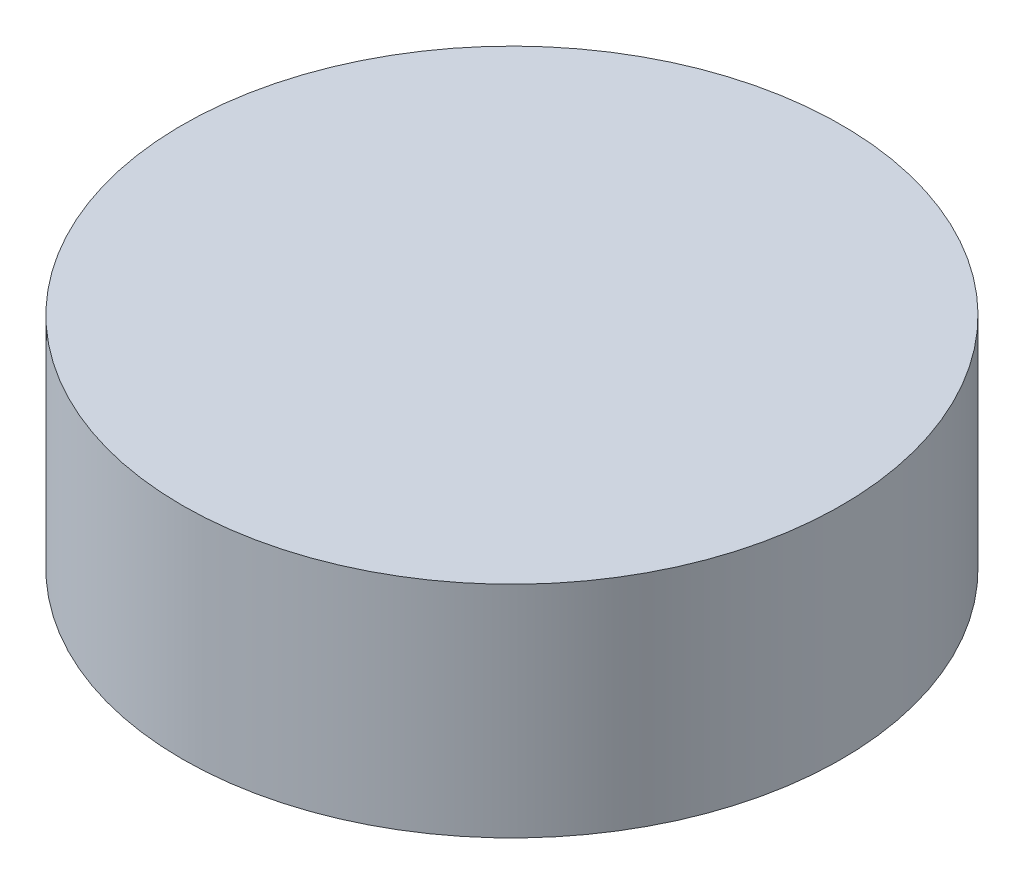
from build123d import *

# Parameters (mm, degrees)
SKETCH1_R           = 1.5
BOSS_EXTRUDE1_DEPTH = 1


with BuildPart() as part:
    # Sketch1 → Boss-Extrude1 (new body)
    with BuildSketch(Plane(origin=(0, 0, 0), x_dir=(1, 0, 0), z_dir=(0, 1, 0))):
        Circle(SKETCH1_R)
    extrude(amount=BOSS_EXTRUDE1_DEPTH)


solid = part.part
